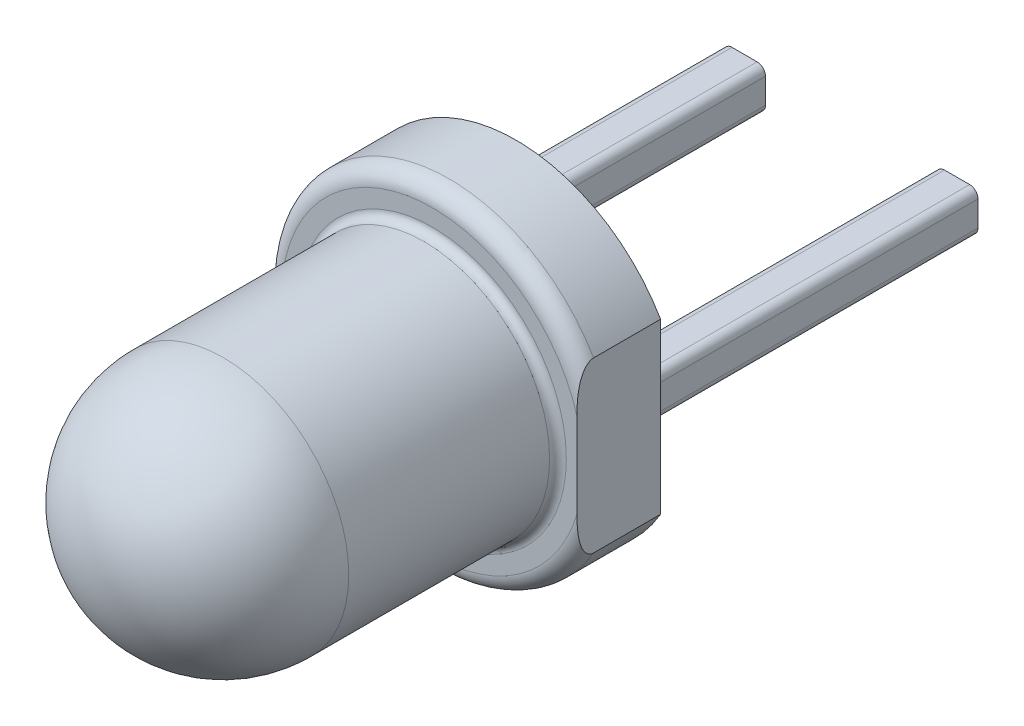
from build123d import *

# Parameters (mm, degrees)
SKETCH1_R           = 2
BOSS_EXTRUDE1_DEPTH = 1
SKETCH2_R           = 1.5
BOSS_EXTRUDE2_DEPTH = 4
FILLET1_R           = 1.5
SKETCH3_W           = 0.5
SKETCH3_H           = 0.5
BOSS_EXTRUDE3_DEPTH = 4
FILLET2_R           = 0.2
FILLET3_R           = 0.1
FILLET4_R           = 0.1
CUT_EXTRUDE1_DEPTH  = 6


with BuildPart() as part:
    # Sketch1 → Boss-Extrude1 (new body)
    with BuildSketch(Plane.XY):
        Circle(SKETCH1_R)
    extrude(amount=BOSS_EXTRUDE1_DEPTH)

    # Sketch2 → Boss-Extrude2 (add)
    with BuildSketch(Plane.XY.offset(1)):
        Circle(SKETCH2_R)
    extrude(amount=BOSS_EXTRUDE2_DEPTH)

    # Fillet1
    fillet1_edges = [part.edges().sort_by_distance(p)[0] for p in [
        (-1.5, 0, 5),
    ]]
    fillet(fillet1_edges, radius=FILLET1_R)

    # Sketch3 → Boss-Extrude3 (add)
    with BuildSketch(Plane(origin=(0, 0, 0), x_dir=(-1, 0, 0), z_dir=(0, 0, -1))):
        with Locations((-1.27, 0)):
            Rectangle(SKETCH3_W, SKETCH3_H)
        with Locations((1.27, 0)):
            Rectangle(SKETCH3_W, SKETCH3_H)
    extrude(amount=BOSS_EXTRUDE3_DEPTH)

    # Fillet2
    fillet2_edges = [part.edges().sort_by_distance(p)[0] for p in [
        (-2, 0, 1),
    ]]
    fillet(fillet2_edges, radius=FILLET2_R)

    # Fillet3
    fillet3_edges = [part.edges().sort_by_distance(p)[0] for p in [
        (-1.5, 0, 1),
    ]]
    fillet(fillet3_edges, radius=FILLET3_R)

    # Fillet4
    fillet4_edges = [part.edges().sort_by_distance(p)[0] for p in [
        (1.02, -0.25, -2),
        (1.02, 0.25, -2),
        (1.52, 0.25, -2),
        (1.52, -0.25, -2),
        (-1.52, -0.25, -2),
        (-1.52, 0.25, -2),
        (-1.02, 0.25, -2),
        (-1.02, -0.25, -2),
    ]]
    fillet(fillet4_edges, radius=FILLET4_R)

    # Sketch5 → Cut-Extrude1 (cut, through all)
    with BuildSketch(Plane(origin=(0, 0, 0), x_dir=(-1, 0, 0), z_dir=(0, 0, -1))):
        with BuildLine():
            Line((-1.726643001, -1.009308647), (-1.726643001, 1.009308647))
            ThreePointArc((-1.726643001, 1.009308647), (-2, 0), (-1.726643001, -1.009308647))
        make_face()
    extrude(amount=-CUT_EXTRUDE1_DEPTH, mode=Mode.SUBTRACT)


solid = part.part
